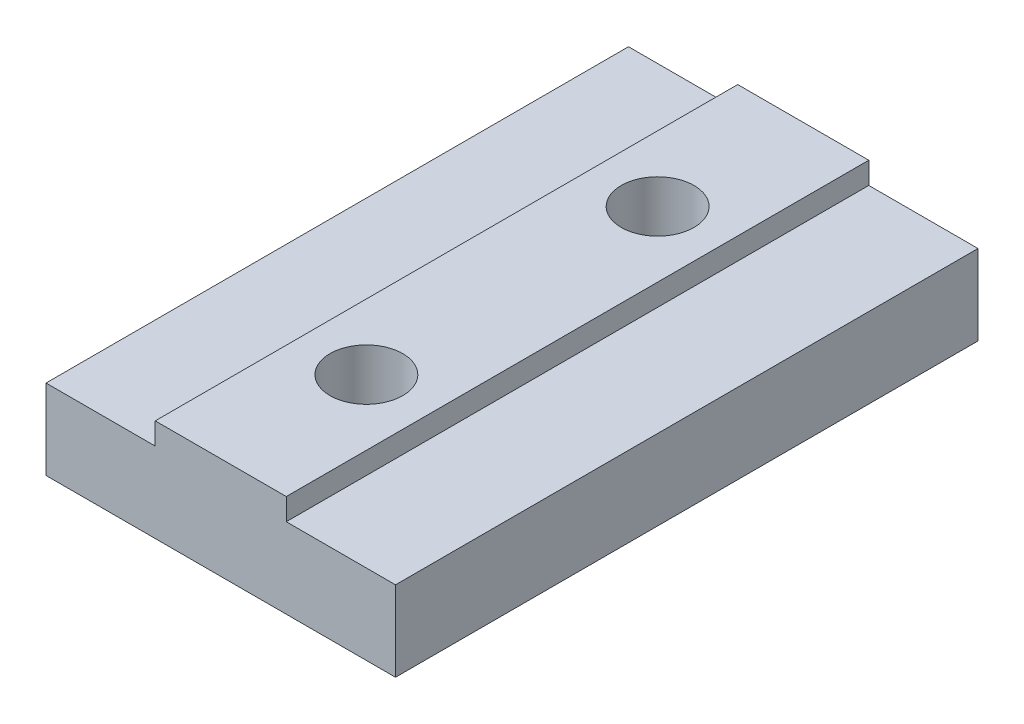
from build123d import *

# Parameters (mm, degrees)
BOSS_EXTRU_1_DEPTH      = 40
ESQUISSE2_R             = 2.5
ENL_V_MAT_EXTRU_1_DEPTH = 8


with BuildPart() as part:
    # Esquisse1 → Boss.-Extru.1 (new body)
    with BuildSketch(Plane.XY):
        Polygon((24, 5.5), (16.5, 5.5), (16.5, 7), (7.5, 7), (7.5, 5.5), (0, 5.5), (0, 0), (24, 0), align=None)
    extrude(amount=BOSS_EXTRU_1_DEPTH)

    # Esquisse2 → Enlèv. mat.-Extru.1 (cut, through all)
    with BuildSketch(Plane(origin=(0, 7, 0), x_dir=(1, 0, 0), z_dir=(0, 1, 0))):
        with Locations((12, -10)):
            Circle(ESQUISSE2_R)
        with Locations((12, -30)):
            Circle(ESQUISSE2_R)
    extrude(amount=-ENL_V_MAT_EXTRU_1_DEPTH, mode=Mode.SUBTRACT)


solid = part.part
